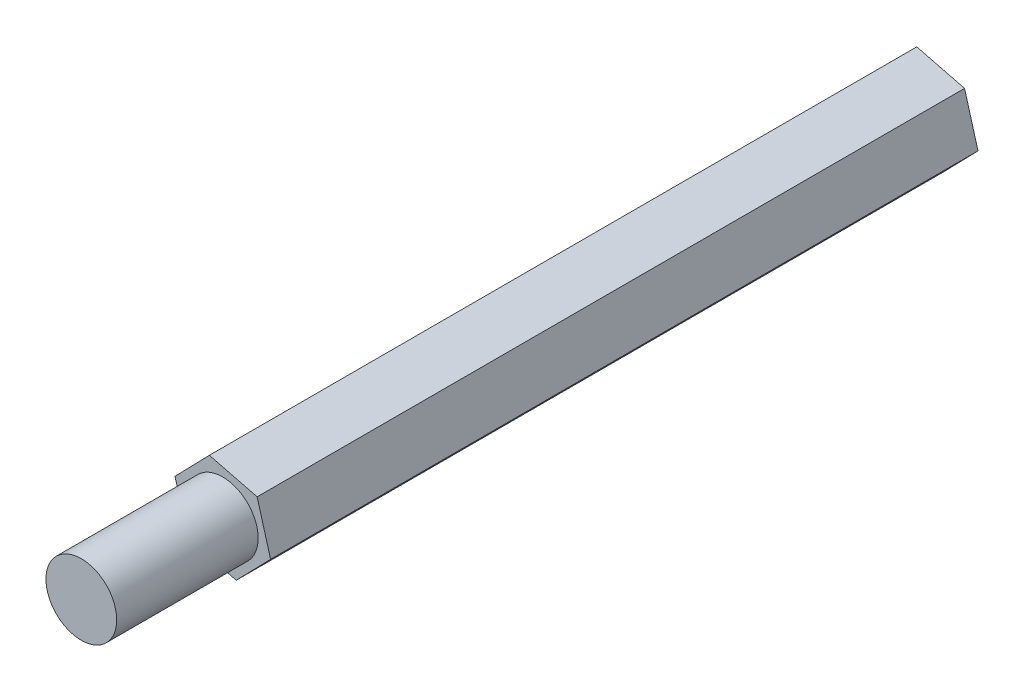
from build123d import *

# Parameters (mm, degrees)
SKETCH_1_R      = 1.5
EXTRUDE_1_DEPTH = 6
EXTRUDE_2_DEPTH = 30


with BuildPart() as part:
    # 草图1 → 凸台-拉伸1 (new body)
    with BuildSketch(Plane.XY):
        Circle(SKETCH_1_R)
    extrude(amount=EXTRUDE_1_DEPTH)

    # 草图2 → 凸台-拉伸2 (add)
    with BuildSketch(Plane(origin=(0, 0, 0), x_dir=(-1, 0, 0), z_dir=(0, 0, -1))):
        Polygon((1.456280061, -1.49922127), (2.026503736, 0.511564893), (0.570223675, 2.010786163), (-1.456280061, 1.49922127), (-2.026503736, -0.511564893), (-0.570223675, -2.010786163), align=None)
    extrude(amount=EXTRUDE_2_DEPTH)


solid = part.part
